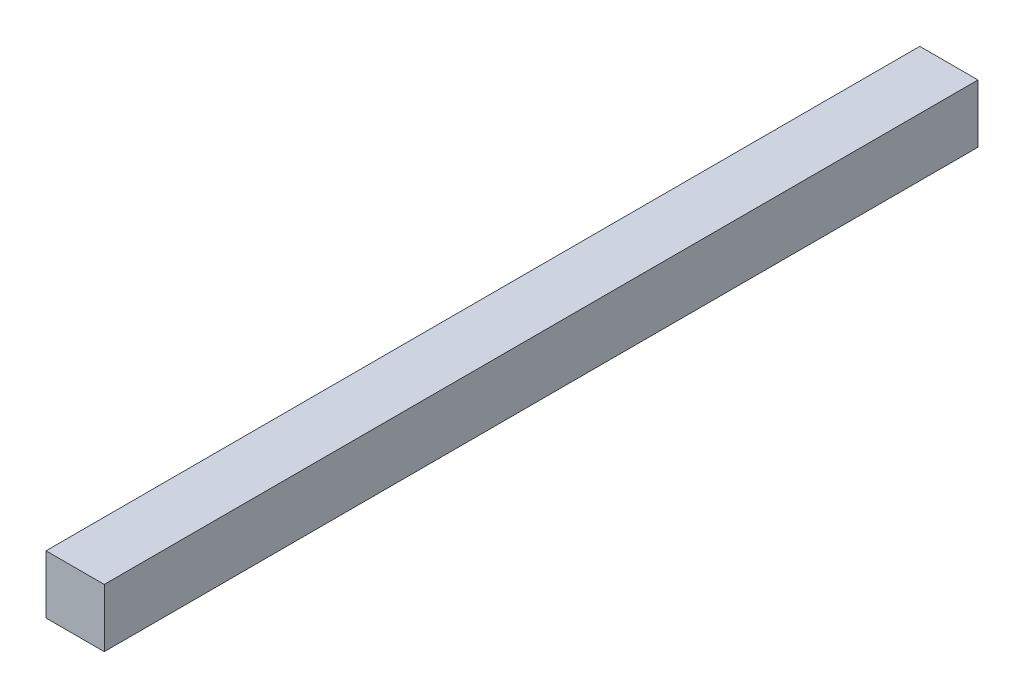
from build123d import *

# Parameters (mm, degrees)
SKETCH7_W           = 20.32
SKETCH7_H           = 20.32
BOSS_EXTRUDE3_DEPTH = 152.4


with BuildPart() as part:
    # Sketch7 → Boss-Extrude3 (new body, symmetric)
    with BuildSketch(Plane.XY):
        Rectangle(SKETCH7_W, SKETCH7_H)
    extrude(amount=BOSS_EXTRUDE3_DEPTH, both=True)


solid = part.part
